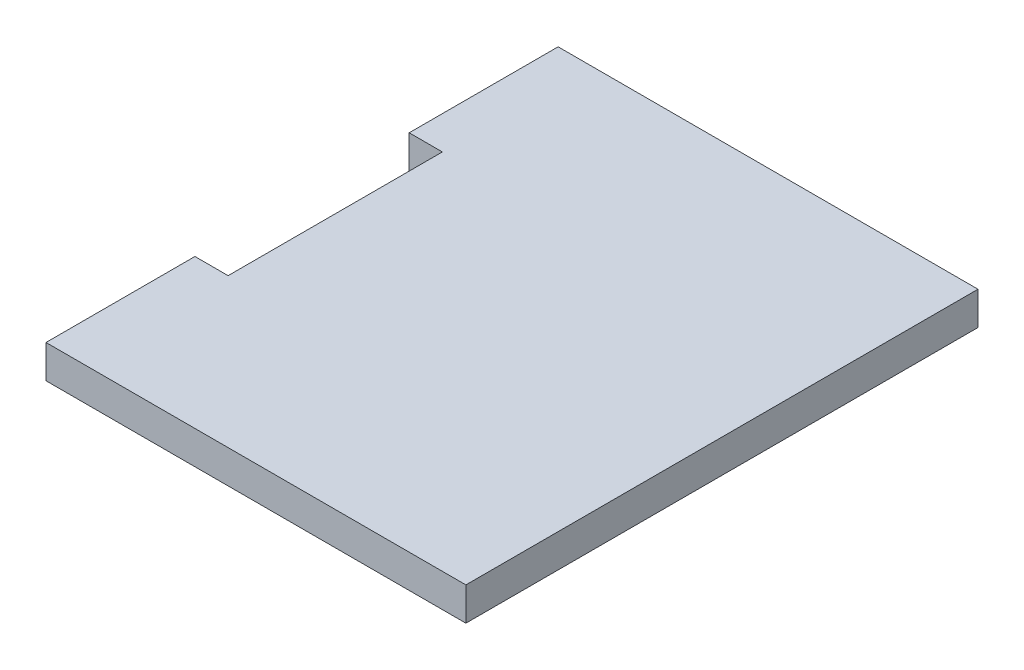
from build123d import *

# Parameters (mm, degrees)
BOSS_EXTRUDE1_DEPTH = 3.175


with BuildPart() as part:
    # Sketch1 → Boss-Extrude1 (new body)
    with BuildSketch(Plane(origin=(0, 0, 0), x_dir=(1, 0, 0), z_dir=(0, 1, 0))):
        Polygon((-40.175, 0), (0, 0), (0, 49), (-40.175, 49), (-40.175, 34.75), (-37, 34.75), (-37, 14.25), (-40.175, 14.25), align=None)
    extrude(amount=BOSS_EXTRUDE1_DEPTH)


solid = part.part
